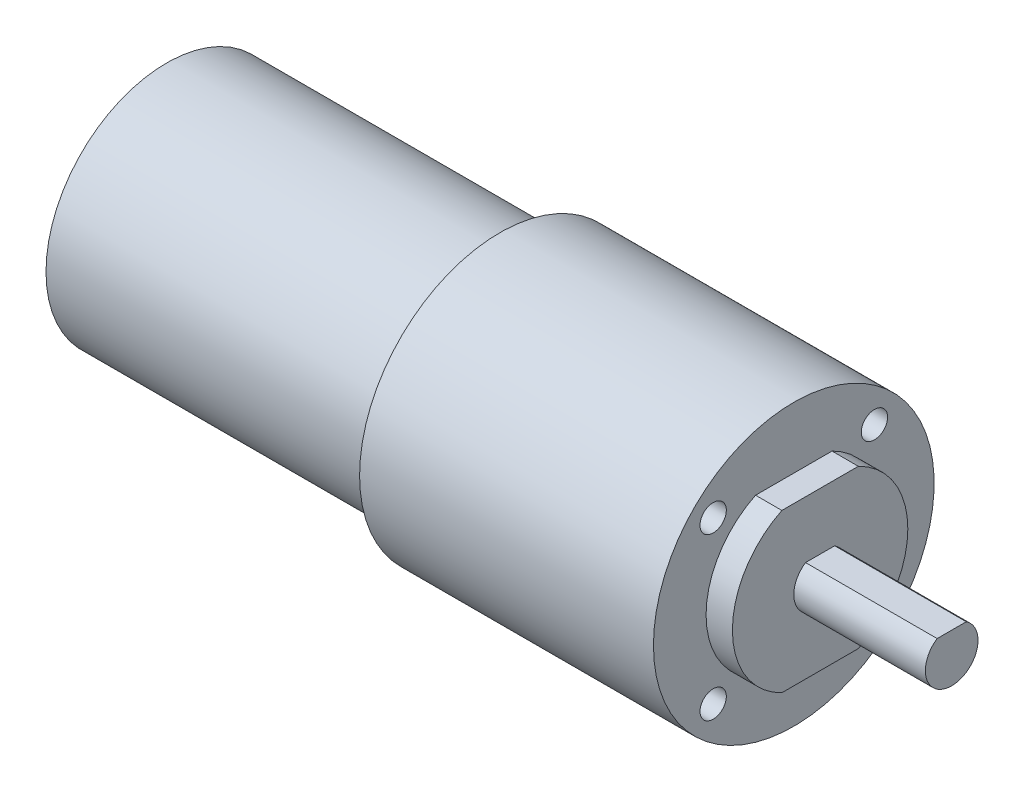
from build123d import *

# Parameters (mm, degrees)
MEPLATFIXING_DEPTH                 = 3
MEPLATROTOR_DEPTH                  = 15
ESQUISSE4_R                        = 1.5
FIXINGHOLE_DEPTH                   = 5
FIXINGHOLECIRCULARREPETITION_COUNT = 4


with BuildPart() as part:
    # Esquisse1 → Révolution1 (revolve)
    with BuildSketch(Plane.XY):
        Polygon((-38, 13.75), (0, 13.75), (0, 16), (33.5, 16), (33.5, 10), (36.5, 10), (36.5, 3), (51.5, 3), (51.5, 0), (-38, 0), align=None)
    revolve(axis=Axis((-42.475, 0, 0), (1, 0, 0)))

    # Esquisse2 → MeplatFixing (cut)
    with BuildSketch(Plane(origin=(36.5, 0, 0), x_dir=(0, 0, -1), z_dir=(1, 0, 0))):
        with BuildLine():
            Line((-4.358898944, 9), (4.358898944, 9))
            ThreePointArc((4.358898944, 9), (0, 10), (-4.358898944, 9))
        make_face()
        with BuildLine():
            Line((-4.358898944, -9), (4.358898944, -9))
            ThreePointArc((4.358898944, -9), (0, -10), (-4.358898944, -9))
        make_face()
    extrude(amount=-MEPLATFIXING_DEPTH, mode=Mode.SUBTRACT)

    # Esquisse3 → MeplatRotor (cut)
    with BuildSketch(Plane(origin=(51.5, 0, 0), x_dir=(0, 0, -1), z_dir=(1, 0, 0))):
        with BuildLine():
            Line((-1.658312395, 2.5), (1.658312395, 2.5))
            ThreePointArc((1.658312395, 2.5), (0, 3), (-1.658312395, 2.5))
        make_face()
    extrude(amount=-MEPLATROTOR_DEPTH, mode=Mode.SUBTRACT)

    # Esquisse4 → FixingHole (cut)
    with BuildSketch(Plane(origin=(33.5, 0, 0), x_dir=(0, 0, -1), z_dir=(1, 0, 0))):
        with Locations((9.192388155, 9.192388155)):
            Circle(ESQUISSE4_R)
    fixinghole = extrude(amount=-FIXINGHOLE_DEPTH, mode=Mode.SUBTRACT)

    # FixingHoleCircularRepetition: FixingHole ×4 about axis
    fixingholecircularrepetition_axis = Axis((0, 0, 0), (1, 0, 0))
    for i in range(1, FIXINGHOLECIRCULARREPETITION_COUNT):
        add(fixinghole.rotate(fixingholecircularrepetition_axis, i * 360 / FIXINGHOLECIRCULARREPETITION_COUNT), mode=Mode.SUBTRACT)


solid = part.part
